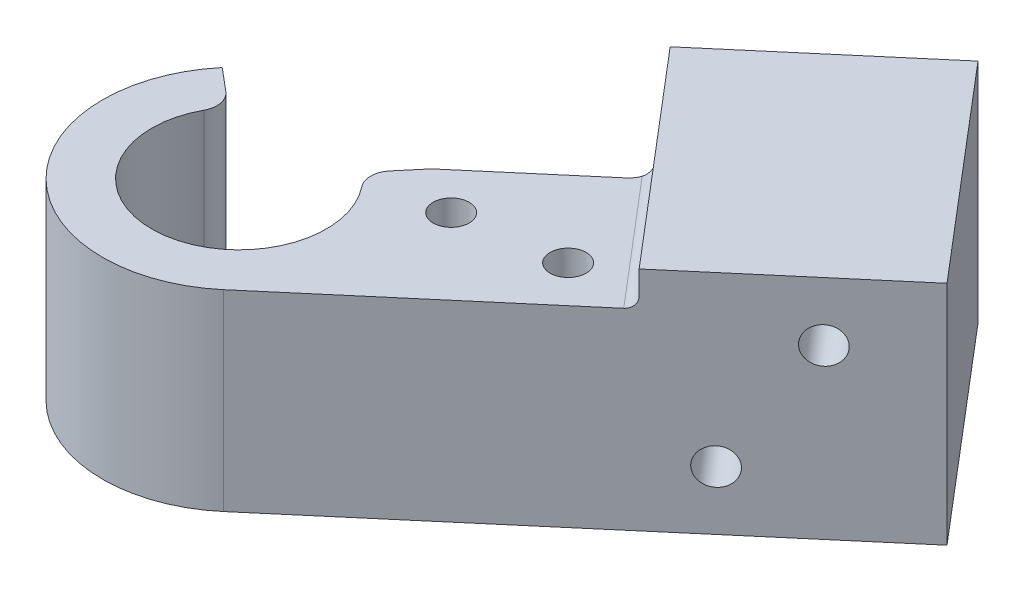
from build123d import *

# Parameters (mm, degrees)
SKETCH1_R                      = 12.5
BOSS_EXTRUDE1_DEPTH            = 17.6
SKETCH2_R                      = 6.875
CUT_EXTRUDE1_DEPTH             = 50.8
SKETCH3_R                      = 8
CUT_EXTRUDE3_DEPTH             = 15.6
CUT_EXTRUDE4_DEPTH             = 25.945139807
BOSS_EXTRUDE2_DEPTH            = 17.6
FILLET1_R                      = 2
SKETCH6_W                      = 25
SKETCH6_H                      = 20.775
BOSS_EXTRUDE3_DEPTH            = 20
M4X0_7_TAPPED_HOLE2_AT_2_COUNT = 2
M4X0_7_TAPPED_HOLE2_AT_2_PITCH = 12.206555616
M4X0_7_TAPPED_HOLE1_D          = 3.3
M4X0_7_TAPPED_HOLE1_DEPTH      = 7
M4X0_7_TAPPED_HOLE1_TIP        = 0.991420021
FILLET4_R                      = 1
FILLET6_R                      = 1
FILLET7_R                      = 2


with BuildPart() as part:
    # Sketch1 → Boss-Extrude1 (new body)
    with BuildSketch(Plane(origin=(0, 0, 0), x_dir=(1, 0, 0), z_dir=(0, 1, 0))):
        with Locations(Location((0, 0, 0), (0, 0, 270))):
            Circle(SKETCH1_R)
    extrude(amount=BOSS_EXTRUDE1_DEPTH)

    # Sketch2 → Cut-Extrude1 (cut)
    with BuildSketch(Plane(origin=(0, 17.6, 0), x_dir=(1, 0, 0), z_dir=(0, 1, 0))):
        with Locations(Location((0, 0, 0), (0, 0, 270))):
            Circle(SKETCH2_R)
    extrude(amount=-CUT_EXTRUDE1_DEPTH, mode=Mode.SUBTRACT)

    # Sketch3 → Cut-Extrude3 (cut)
    with BuildSketch(Plane(origin=(0, 17.6, 0), x_dir=(1, 0, 0), z_dir=(0, 1, 0))):
        with Locations(Location((0, 0, 0), (0, 0, 270))):
            Circle(SKETCH3_R)
    extrude(amount=-CUT_EXTRUDE3_DEPTH, mode=Mode.SUBTRACT)

    # Sketch4 → Cut-Extrude4 (cut, through all)
    with BuildSketch(Plane(origin=(0, 17.6, 0), x_dir=(1, 0, 0), z_dir=(0, 1, 0))):
        with BuildLine():
            ThreePointArc((-6.128355545, 5.142300877), (-0.697245942, 7.969557585), (5.142300877, 6.128355545))
            Line((5.142300877, 6.128355545), (8.034845121, 9.575555539))
            ThreePointArc((8.034845121, 9.575555539), (-1.089446784, 12.452433726), (-9.575555539, 8.034845121))
            Line((-9.575555539, 8.034845121), (-6.128355545, 5.142300877))
        make_face()
    extrude(amount=-CUT_EXTRUDE4_DEPTH, mode=Mode.SUBTRACT)

    # Sketch5 → Boss-Extrude2 (add, through all)
    with BuildSketch(Plane(origin=(0, 17.6, 0), x_dir=(1, 0, 0), z_dir=(0, 1, 0))):
        with BuildLine():
            Line((28.663977541, 7.976615292), (19.211771381, 19.085584129))
            Line((19.211771381, 19.085584129), (8.034845121, 9.575555539))
            ThreePointArc((8.034845121, 9.575555539), (12.499926406, 0.042893271), (8.100371818, -9.520187835))
            Line((8.100371818, -9.520187835), (28.663977541, 7.976615292))
        make_face()
    extrude(amount=-BOSS_EXTRUDE2_DEPTH)

    # Fillet1
    fillet1_edges = [part.edges().sort_by_distance(p)[0] for p in [
        (5.142300877, 9.8, -6.128355545),
        (-6.128355545, 9.8, -5.142300877),
    ]]
    fillet(fillet1_edges, radius=FILLET1_R)

    # Sketch6 → Boss-Extrude3 (add)
    with BuildSketch(Plane(origin=(20.563605723, 0, -17.496803127), x_dir=(-0.6480297454391464, 0, -0.7616150267858922), z_dir=(0.7616150267858922, 0, -0.6480297454391464))):
        with Locations((0, 10.3875)):
            Rectangle(SKETCH6_W, SKETCH6_H)
    extrude(amount=BOSS_EXTRUDE3_DEPTH)

    # Sketch9 → M4x0.7 Tapped Hole2 (revolve, cut)
    with BuildSketch(Plane(origin=(21.602614227, 15.3875, -34.793347907), x_dir=(-0.7616150267858922, 0, 0.6480297454391463), z_dir=(0, 1, 0))):
        Polygon((0, 0), (0, 7.991420021), (1.65, 7), (1.65, 0), align=None)
    m4x0_7_tapped_hole2 = revolve(axis=Axis((17.487625343, 15.3875, -39.629603327), (0.6480297454391463, 0, 0.7616150267858921)), mode=Mode.SUBTRACT)

    # M4x0.7 Tapped Hole2 at 2: M4x0.7 Tapped Hole2 ×2
    with Locations(*[Vector(-0.43675753876297707, -0.8192319205190405, 0.3716206570367036) * (i * M4X0_7_TAPPED_HOLE2_AT_2_PITCH) for i in range(1, M4X0_7_TAPPED_HOLE2_AT_2_COUNT)]):
        add(m4x0_7_tapped_hole2, mode=Mode.SUBTRACT)

    # Mirror1: M4x0.7 Tapped Hole2 across plane
    add(m4x0_7_tapped_hole2.mirror(Plane(origin=(0, 0, 0), x_dir=(-0.7616150267858919, 0, 0.6480297454391465), z_dir=(-0.6480297454391465, 0, -0.761615026785892))), mode=Mode.SUBTRACT)

    # Mirror1 copy 1 sketch → Mirror1 copy 1 (revolve, cut)
    with BuildSketch(Plane(origin=(32.472052675, 5.3875, -11.216764019), x_dir=(-0.7616150267858918, 0, 0.6480297454391468), z_dir=(0, 1, 0))):
        Polygon((0, 0), (0, -7.991420021), (1.65, -7), (1.65, 0), align=None)
    revolve(axis=Axis((36.587041559, 5.3875, -6.380508599), (0.6480297454391466, 0, 0.7616150267858917)), mode=Mode.SUBTRACT)

    # M4x0.7 Tapped Hole1
    with Locations(Plane(origin=(0, 17.6, 0), x_dir=(1, 0, 0), z_dir=(0, 1, 0))):
        with Locations((21.749873691, 8.386913416), (12.41680475, 7.010750587)):
            Hole(M4X0_7_TAPPED_HOLE1_D / 2, depth=M4X0_7_TAPPED_HOLE1_DEPTH)
            with Locations((0, 0, -(M4X0_7_TAPPED_HOLE1_DEPTH + M4X0_7_TAPPED_HOLE1_TIP / 2))):  # 118° drill point
                Cone(0, M4X0_7_TAPPED_HOLE1_D / 2, M4X0_7_TAPPED_HOLE1_TIP, mode=Mode.SUBTRACT)

    # Fillet4
    fillet4_edges = [part.edges().sort_by_distance(p)[0] for p in [
        (23.937874461, 17.6, -13.531099711),
    ]]
    fillet(fillet4_edges, radius=FILLET4_R)

    # Fillet6
    fillet6_edges = [part.edges().sort_by_distance(p)[0] for p in [
        (-6.128355545, 1, -5.142300877),
        (5.142300877, 1, -6.128355545),
    ]]
    fillet(fillet6_edges, radius=FILLET6_R)

    # Fillet7
    fillet7_edges = [part.edges().sort_by_distance(p)[0] for p in [
        (19.211771381, 9.3, -19.085584129),
    ]]
    fillet(fillet7_edges, radius=FILLET7_R)


solid = part.part
